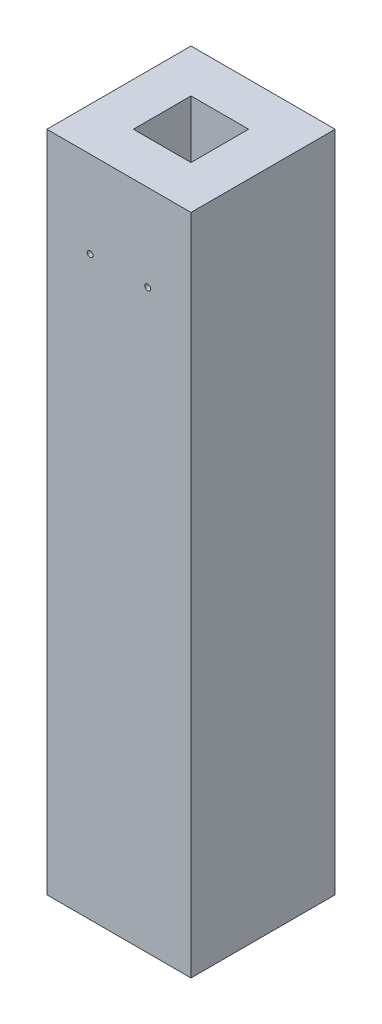
from build123d import *

# Parameters (mm, degrees)
SKETCH1_W           = 50
SKETCH1_H           = 50
BOSS_EXTRUDE1_DEPTH = 230
SKETCH2_W           = 30
SKETCH2_H           = 25
BOSS_EXTRUDE2_DEPTH = 10
SKETCH3_R           = 5
CUT_EXTRUDE1_DEPTH  = 100
SKETCH4_W           = 20
SKETCH4_H           = 20
CUT_EXTRUDE2_DEPTH  = 21
SKETCH5_R           = 1
CUT_EXTRUDE3_DEPTH  = 15


with BuildPart() as part:
    # Sketch1 → Boss-Extrude1 (new body)
    with BuildSketch(Plane(origin=(0, 0, 0), x_dir=(1, 0, 0), z_dir=(0, 1, 0))):
        Rectangle(SKETCH1_W, SKETCH1_H)
    extrude(amount=BOSS_EXTRUDE1_DEPTH)

    # Sketch2 → Boss-Extrude2 (add)
    with BuildSketch(Plane(origin=(0, 0, 0), x_dir=(-1, 0, 0), z_dir=(0, -1, 0))):
        Rectangle(SKETCH2_W, SKETCH2_H)
    extrude(amount=BOSS_EXTRUDE2_DEPTH)

    # Sketch3 → Cut-Extrude1 (cut)
    with BuildSketch(Plane(origin=(0, -10, 0), x_dir=(-1, 0, 0), z_dir=(0, -1, 0))):
        Circle(SKETCH3_R)
    extrude(amount=-CUT_EXTRUDE1_DEPTH, mode=Mode.SUBTRACT)

    # Sketch4 → Cut-Extrude2 (cut)
    with BuildSketch(Plane(origin=(0, 230, 0), x_dir=(1, 0, 0), z_dir=(0, 1, 0))):
        Rectangle(SKETCH4_W, SKETCH4_H)
    extrude(amount=-CUT_EXTRUDE2_DEPTH, mode=Mode.SUBTRACT)

    # Sketch5 → Cut-Extrude3 (cut)
    with BuildSketch(Plane.XY.offset(25)):
        with Locations((10, 200)):
            Circle(SKETCH5_R)
        with Locations((-10, 200)):
            Circle(SKETCH5_R)
    extrude(amount=-CUT_EXTRUDE3_DEPTH, mode=Mode.SUBTRACT)


solid = part.part
